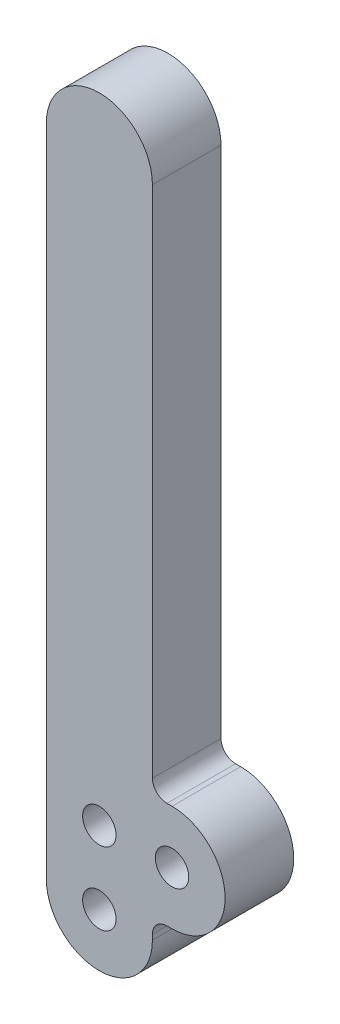
from build123d import *

# Parameters (mm, degrees)
SKETCH1_R           = 1.4605
BOSS_EXTRUDE1_DEPTH = 5.9944


with BuildPart() as part:
    # Sketch1 → Boss-Extrude1 (new body)
    with BuildSketch(Plane.XY):
        with BuildLine():
            Line((4.6355, 0), (4.6355, 0.4445))
            ThreePointArc((4.6355, 0.4445), (5.007474388, 1.342525612), (5.9055, 1.7145))
            Line((5.9055, 1.7145), (6.35, 1.7145))
            ThreePointArc((6.35, 1.7145), (10.9855, 6.35), (6.35, 10.9855))
            Line((6.35, 10.9855), (5.9055, 10.9855))
            ThreePointArc((5.9055, 10.9855), (5.007474388, 11.357474388), (4.6355, 12.2555))
            Line((4.6355, 12.2555), (4.6355, 57.15))
            ThreePointArc((4.6355, 57.15), (0, 61.7855), (-4.6355, 57.15))
            Line((-4.6355, 57.15), (-4.6355, 0))
            ThreePointArc((-4.6355, 0), (0, -4.6355), (4.6355, 0))
        make_face()
        Circle(SKETCH1_R, mode=Mode.SUBTRACT)
        with Locations((0, 6.35)):
            Circle(SKETCH1_R, mode=Mode.SUBTRACT)
        with Locations((6.35, 6.35)):
            Circle(SKETCH1_R, mode=Mode.SUBTRACT)
    extrude(amount=BOSS_EXTRUDE1_DEPTH)


solid = part.part
